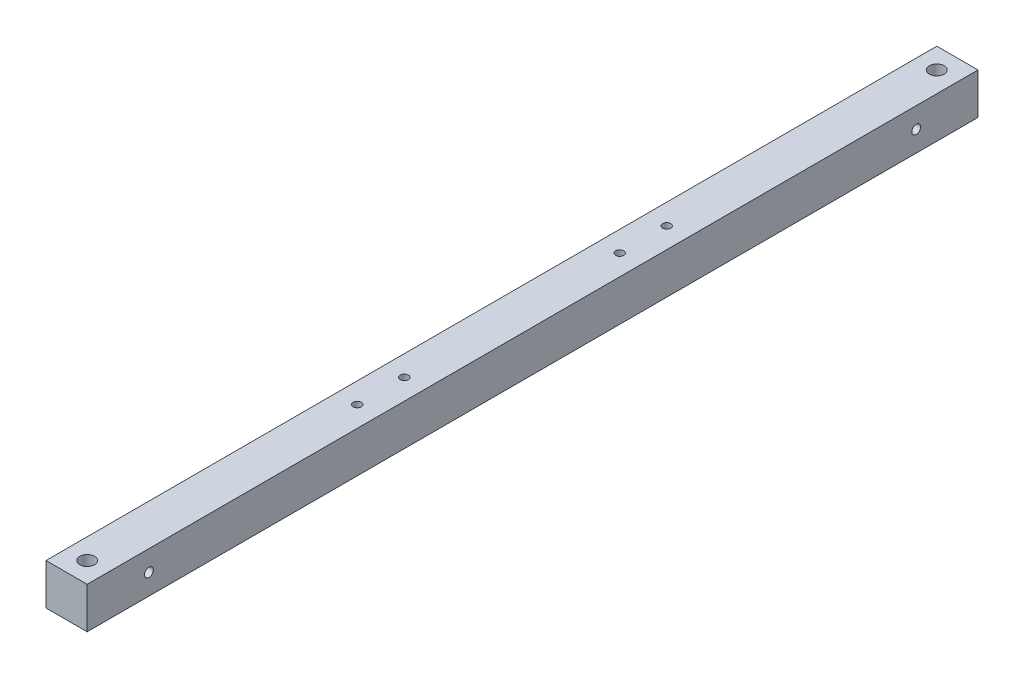
from build123d import *

# Parameters (mm, degrees)
IZIM1_W                     = 28
IZIM1_H                     = 28
Y_KSEKLIK_EKSTR_ZYON1_DEPTH = 606
IZIM2_R                     = 3
KES_EKSTR_ZYON1_DEPTH       = 40
IZIM4_R                     = 5
KES_EKSTR_ZYON2_DEPTH       = 7
IZIM5_R                     = 3
KES_EKSTR_ZYON3_DEPTH       = 1
KES_EKSTR_ZYON3_DEPTH_BACK  = 29
IZIM6_R                     = 5
KES_EKSTR_ZYON4_DEPTH       = 7
IZIM8_R                     = 2.75
KES_EKSTR_ZYON6_DEPTH       = 29


with BuildPart() as part:
    # Çizim1 → Yükseklik-Ekstrüzyon1 (new body)
    with BuildSketch(Plane.XY):
        Rectangle(IZIM1_W, IZIM1_H)
    extrude(amount=Y_KSEKLIK_EKSTR_ZYON1_DEPTH)

    # Çizim2 → Kes-Ekstrüzyon1 (cut)
    with BuildSketch(Plane(origin=(14, 0, 0), x_dir=(0, 0, -1), z_dir=(1, 0, 0))):
        with Locations((-42, 0)):
            Circle(IZIM2_R)
        with Locations((-564, 0)):
            Circle(IZIM2_R)
    extrude(amount=-KES_EKSTR_ZYON1_DEPTH, mode=Mode.SUBTRACT)

    # Çizim4 → Kes-Ekstrüzyon2 (cut)
    with BuildSketch(Plane.ZY.offset(14)):
        with Locations((42, 0)):
            Circle(IZIM4_R)
        with Locations((564, 0)):
            Circle(IZIM4_R)
    extrude(amount=-KES_EKSTR_ZYON2_DEPTH, mode=Mode.SUBTRACT)

    # Çizim5 → Kes-Ekstrüzyon3 (cut, two sides)
    with BuildSketch(Plane(origin=(0, 14, 0), x_dir=(1, 0, 0), z_dir=(0, 1, 0))) as kes_ekstr_zyon3_sk:
        with Locations((0, -592)):
            Circle(IZIM5_R)
        with Locations((0, -14)):
            Circle(IZIM5_R)
    extrude(amount=KES_EKSTR_ZYON3_DEPTH, mode=Mode.SUBTRACT)
    extrude(kes_ekstr_zyon3_sk.sketch, amount=-KES_EKSTR_ZYON3_DEPTH_BACK, mode=Mode.SUBTRACT)

    # Çizim6 → Kes-Ekstrüzyon4 (cut)
    with BuildSketch(Plane(origin=(0, 14, 0), x_dir=(1, 0, 0), z_dir=(0, 1, 0))):
        with Locations((0, -14)):
            Circle(IZIM6_R)
        with Locations((0, -592)):
            Circle(IZIM6_R)
    extrude(amount=-KES_EKSTR_ZYON4_DEPTH, mode=Mode.SUBTRACT)

    # Çizim8 → Kes-Ekstrüzyon6 (cut, through all)
    with BuildSketch(Plane(origin=(0, 14, 0), x_dir=(1, 0, 0), z_dir=(0, 1, 0))):
        with Locations((0, -408.25)):
            Circle(IZIM8_R)
        with Locations((0, -376.25)):
            Circle(IZIM8_R)
        with Locations((0, -229.75)):
            Circle(IZIM8_R)
        with Locations((0, -197.75)):
            Circle(IZIM8_R)
    extrude(amount=-KES_EKSTR_ZYON6_DEPTH, mode=Mode.SUBTRACT)


solid = part.part
